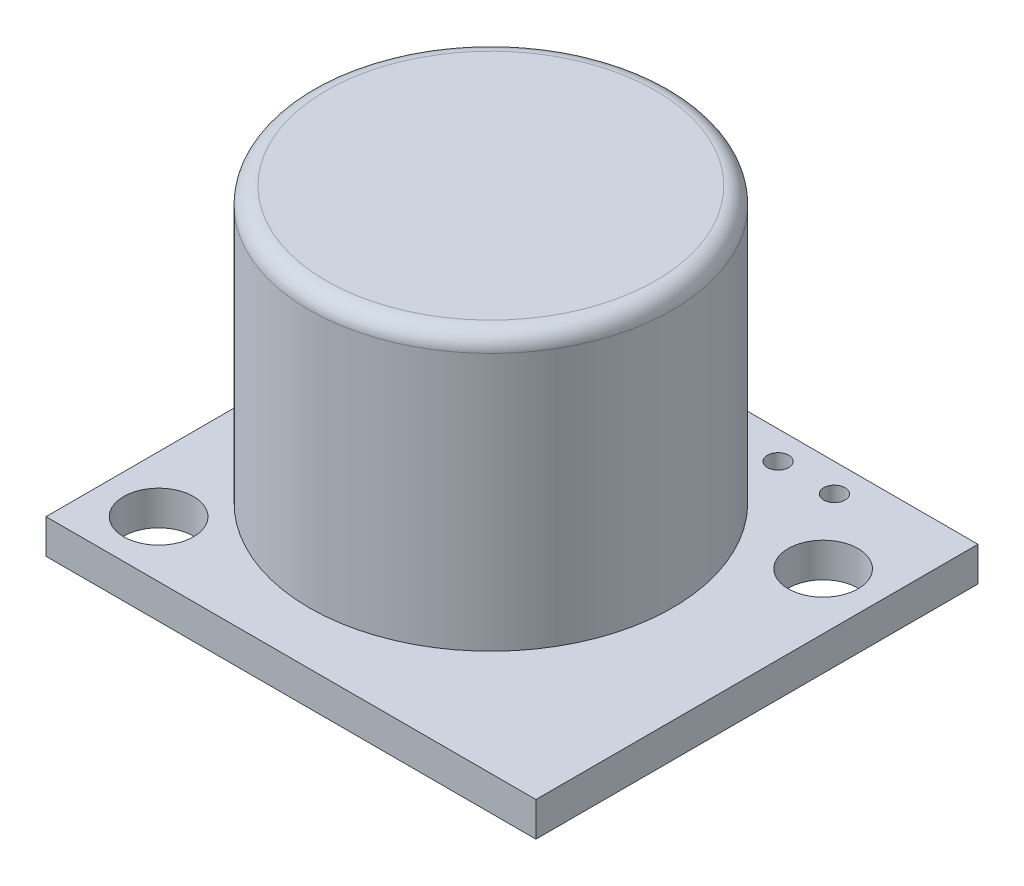
from build123d import *

# Parameters (mm, degrees)
SKETCH2_W           = 22.098
SKETCH2_H           = 19.939
BOSS_EXTRUDE1_DEPTH = 1.5494
BOSS_EXTRUDE3_DEPTH = 1.5494
SKETCH7_R           = 8.1915
BOSS_EXTRUDE4_DEPTH = 12.3952
SKETCH8_R           = 1.5748
SKETCH8_R_2         = 0.4826
CUT_EXTRUDE1_DEPTH  = 2.5494
FILLET1_R           = 0.762


with BuildPart() as part:
    # Sketch2 → Boss-Extrude1 (new body)
    with BuildSketch(Plane(origin=(0, 0, 0), x_dir=(1, 0, 0), z_dir=(0, 1, 0))):
        with Locations((11.049, 9.9695)):
            Rectangle(SKETCH2_W, SKETCH2_H)
    extrude(amount=BOSS_EXTRUDE1_DEPTH)

    # Sketch6 → Boss-Extrude3 (add)
    with BuildSketch(Plane(origin=(0, 1.5494, 0), x_dir=(1, 0, 0), z_dir=(0, 1, 0))):
        with BuildLine():
            ThreePointArc((16.129, 9.017), (14.641102448, 12.609102448), (11.049, 14.097))
            Line((11.049, 14.097), (11.049, 9.017))
            Line((11.049, 9.017), (11.049, 3.937))
            ThreePointArc((11.049, 3.937), (14.641102448, 5.424897552), (16.129, 9.017))
        make_face()
        with BuildLine():
            Line((11.049, 9.017), (11.049, 14.097))
            ThreePointArc((11.049, 14.097), (5.969, 9.017), (11.049, 3.937))
            Line((11.049, 3.937), (11.049, 9.017))
        make_face()
    extrude(amount=BOSS_EXTRUDE3_DEPTH)

    # Sketch7 → Boss-Extrude4 (add)
    with BuildSketch(Plane(origin=(0, 3.0988, 0), x_dir=(1, 0, 0), z_dir=(0, 1, 0))):
        with Locations((11.049, 9.017)):
            Circle(SKETCH7_R)
    extrude(amount=BOSS_EXTRUDE4_DEPTH)

    # Sketch8 → Cut-Extrude1 (cut, through all)
    with BuildSketch(Plane(origin=(0, 1.5494, 0), x_dir=(1, 0, 0), z_dir=(0, 1, 0))):
        with Locations((19.558, 15.494)):
            Circle(SKETCH8_R)
        with Locations((2.54, 2.54)):
            Circle(SKETCH8_R)
        with Locations((16.891, 18.669)):
            Circle(SKETCH8_R_2)
        with Locations((14.351, 18.669)):
            Circle(SKETCH8_R_2)
        with Locations((11.811, 18.669)):
            Circle(SKETCH8_R_2)
        with Locations((9.271, 18.669)):
            Circle(SKETCH8_R_2)
        with Locations((6.731, 18.669)):
            Circle(SKETCH8_R_2)
        with Locations((4.191, 18.669)):
            Circle(SKETCH8_R_2)
        with Locations((1.651, 18.669)):
            Circle(SKETCH8_R_2)
    extrude(amount=-CUT_EXTRUDE1_DEPTH, mode=Mode.SUBTRACT)

    # Fillet1
    fillet1_edges = [part.edges().sort_by_distance(p)[0] for p in [
        (2.8575, 15.494, -9.017),
    ]]
    fillet(fillet1_edges, radius=FILLET1_R)


solid = part.part
